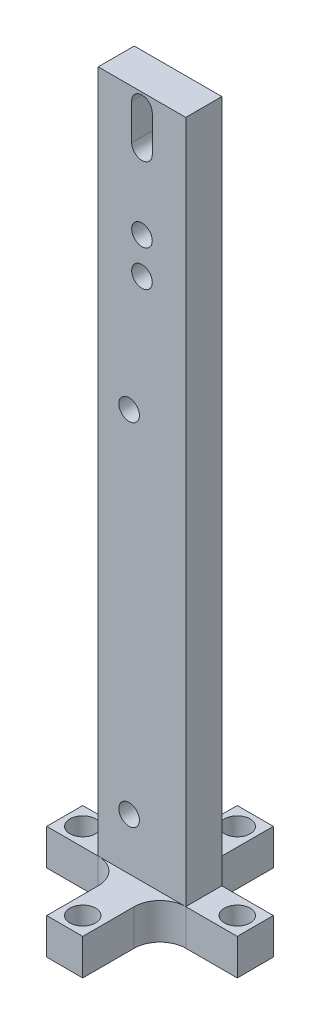
from build123d import *

# Parameters (mm, degrees)
SKETCH1_W           = 17
SKETCH1_H           = 7
BOSS_EXTRUDE1_DEPTH = 139.7
SKETCH2_R           = 2.5
BOSS_EXTRUDE2_DEPTH = 7
FILLET1_R           = 5
SKETCH3_R           = 2
CUT_EXTRUDE1_DEPTH  = 7
SKETCH4_R           = 2
CUT_EXTRUDE2_DEPTH  = 7


with BuildPart() as part:
    # Sketch1 → Boss-Extrude1 (new body)
    with BuildSketch(Plane(origin=(0, 0, 0), x_dir=(1, 0, 0), z_dir=(0, 1, 0))):
        Rectangle(SKETCH1_W, SKETCH1_H)
    extrude(amount=BOSS_EXTRUDE1_DEPTH)

    # Sketch2 → Boss-Extrude2 (add)
    with BuildSketch(Plane(origin=(0, 0, 0), x_dir=(1, 0, 0), z_dir=(0, 1, 0))):
        Polygon((-3.5, 3.5), (-3.5, 18.5), (3.5, 18.5), (3.5, 3.5), (8.5, 3.5), (18.5, 3.5), (18.5, -3.5), (8.5, -3.5), (3.5, -3.5), (3.5, -18.5), (-3.5, -18.5), (-3.5, -3.5), (-8.5, -3.5), (-18.5, -3.5), (-18.5, 3.5), (-8.5, 3.5), align=None)
        with Locations((0, 15)):
            Circle(SKETCH2_R, mode=Mode.SUBTRACT)
        with Locations((15, 0)):
            Circle(SKETCH2_R, mode=Mode.SUBTRACT)
        with Locations((0, -15)):
            Circle(SKETCH2_R, mode=Mode.SUBTRACT)
        with Locations((-15, 0)):
            Circle(SKETCH2_R, mode=Mode.SUBTRACT)
    extrude(amount=BOSS_EXTRUDE2_DEPTH)

    # Fillet1
    fillet1_edges = [part.edges().sort_by_distance(p)[0] for p in [
        (-3.5, 3.5, 3.5),
        (3.5, 3.5, 3.5),
        (3.5, 3.5, -3.5),
        (-3.5, 3.5, -3.5),
    ]]
    fillet(fillet1_edges, radius=FILLET1_R)

    # Sketch3 → Cut-Extrude1 (cut)
    with BuildSketch(Plane.XY.offset(3.5)):
        with Locations((-2.5, 85.072)):
            Circle(SKETCH3_R)
        with Locations((-2.5, 17)):
            Circle(SKETCH3_R)
    extrude(amount=-CUT_EXTRUDE1_DEPTH, mode=Mode.SUBTRACT)

    # Sketch4 → Cut-Extrude2 (cut)
    with BuildSketch(Plane.XY.offset(3.5)):
        with Locations((0, 115.7)):
            Circle(SKETCH4_R)
        with Locations((0, 108.7)):
            Circle(SKETCH4_R)
        with BuildLine():
            Line((2, 137.2), (2, 130.2))
            ThreePointArc((2, 130.2), (0, 128.2), (-2, 130.2))
            Line((-2, 130.2), (-2, 137.2))
            ThreePointArc((-2, 137.2), (0, 139.2), (2, 137.2))
        make_face()
    extrude(amount=-CUT_EXTRUDE2_DEPTH, mode=Mode.SUBTRACT)


solid = part.part
